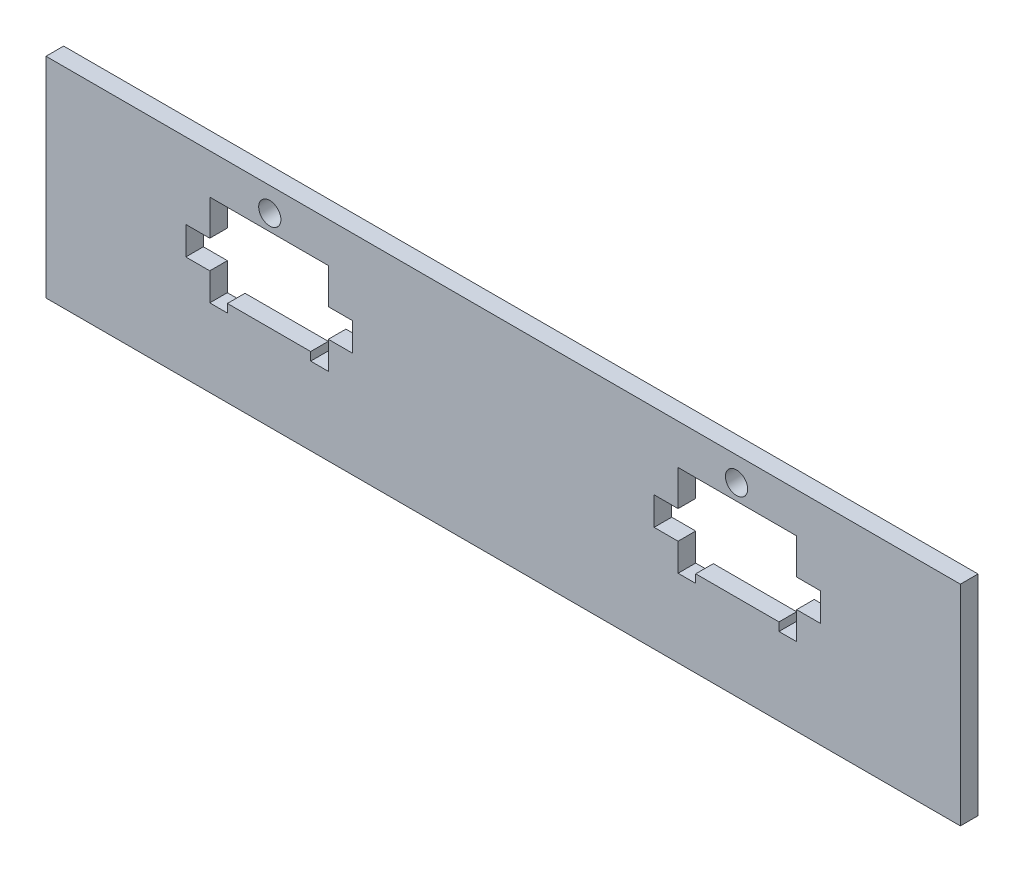
from build123d import *

# Parameters (mm, degrees)
BOSS_EXTRUDE1_DEPTH               = 3.175
SKETCH8_W                         = 36.346
SKETCH8_H                         = 3.175
BOSS_EXTRUDE3_DEPTH               = 3.175
SKETCH7_R                         = 2
LED_HOLE_DEPTH                    = 4.175
SKETCH10_W                        = 36.346
SKETCH10_H                        = 12.319
LOWER_PART_DEPTH                  = 3.175
CUT_EXTRUDE3_DEPTH                = 4.175
SKETCH11_W                        = 4.32
SKETCH11_H                        = 5.08
SKETCH11_W_2                      = 4.315
IR_HOLE_DEPTH                     = 4.175
SKETCH14_W                        = 24.003
SKETCH14_H                        = 37.717280076
SKETCH14_W_2                      = 22
BOSS_EXTRUDE5_DEPTH               = 3.175
SKETCH19_W                        = 3.175
SKETCH19_H                        = 1.5
BOTTOM_GROOVE_FOR_SIDE_PART_DEPTH = 3.175


with BuildPart() as part:
    # Sketch1 → Boss-Extrude1 (new body)
    with BuildSketch(Plane.XY):
        Polygon((-27.39024803, -18.912140652), (-12.39024803, -18.912140652), (-12.39024803, -33.912140652), (-1.71724803, -33.912140652), (-1.71724803, -14.863860576), (-38.06324803, -14.863860576), (-38.06324803, -33.912140652), (-27.39024803, -33.912140652), align=None)
    extrude(amount=-BOSS_EXTRUDE1_DEPTH)

    # Sketch8 → Boss-Extrude3 (add)
    with BuildSketch(Plane.XY):
        with Locations((-19.89024803, -35.499640652)):
            Rectangle(SKETCH8_W, SKETCH8_H)
        with Locations((-19.89024803, -13.276360576)):
            Rectangle(SKETCH8_W, SKETCH8_H)
    extrude(amount=-BOSS_EXTRUDE3_DEPTH)

    # Sketch7 → LED hole (cut, through all)
    with BuildSketch(Plane.XY):
        with Locations((-19.752796976, -16.027063068)):
            Circle(SKETCH7_R)
    extrude(amount=-LED_HOLE_DEPTH, mode=Mode.SUBTRACT)

    # Sketch10 → Lower part (add)
    with BuildSketch(Plane.XY):
        with Locations((-19.89024803, -43.246640652)):
            Rectangle(SKETCH10_W, SKETCH10_H)
    extrude(amount=-LOWER_PART_DEPTH)

    # Sketch12 → Cut-Extrude3 (cut, through all)
    with BuildSketch(Plane(origin=(0, 0, -3.175), x_dir=(-1, 0, 0), z_dir=(0, 0, -1))):
        Polygon((12.39024803, -33.912140652), (12.39024803, -18.912140652), (9.21524803, -18.912140652), (9.21524803, -22.092140652), (9.21524803, -30.737140652), (9.21524803, -33.912140652), align=None)
        Polygon((27.39024803, -18.912140652), (27.39024803, -33.912140652), (30.56524803, -33.912140652), (30.56524803, -30.732140652), (30.56524803, -22.087140652), (30.56524803, -18.912140652), align=None)
    extrude(amount=-CUT_EXTRUDE3_DEPTH, mode=Mode.SUBTRACT)

    # Sketch11 → IR Hole (cut, through all)
    with BuildSketch(Plane.XY):
        with Locations((-32.72524803, -27.872140652)):
            Rectangle(SKETCH11_W, SKETCH11_H)
        with Locations((-7.057813242, -27.872140652)):
            Rectangle(SKETCH11_W_2, SKETCH11_H)
    extrude(amount=-IR_HOLE_DEPTH, mode=Mode.SUBTRACT)

    # Sketch14 → Boss-Extrude5 (add)
    with BuildSketch(Plane(origin=(0, 0, -3.175), x_dir=(-1, 0, 0), z_dir=(0, 0, -1))):
        with Locations((-10.28425197, -30.547500614)):
            Rectangle(SKETCH14_W, SKETCH14_H)
        with Locations((49.06324803, -30.547500614)):
            Rectangle(SKETCH14_W_2, SKETCH14_H)
    extrude(amount=-BOSS_EXTRUDE5_DEPTH)

    # Sketch19 → bottom groove for side part (cut)
    with BuildSketch(Plane.XY):
        with Locations((-28.97774803, -34.662140652)):
            Rectangle(SKETCH19_W, SKETCH19_H)
        with Locations((-10.80274803, -34.662140652)):
            Rectangle(SKETCH19_W, SKETCH19_H)
    extrude(amount=-BOTTOM_GROOVE_FOR_SIDE_PART_DEPTH, mode=Mode.SUBTRACT)

    # Mirror1: part across plane


with BuildPart() as part_1:
    add(part.part)
    add(part.part.mirror(Plane(origin=(22.28575197, 0, 0), x_dir=(0, 0, 1), z_dir=(1, 0, 0))))


solid = part_1.part
